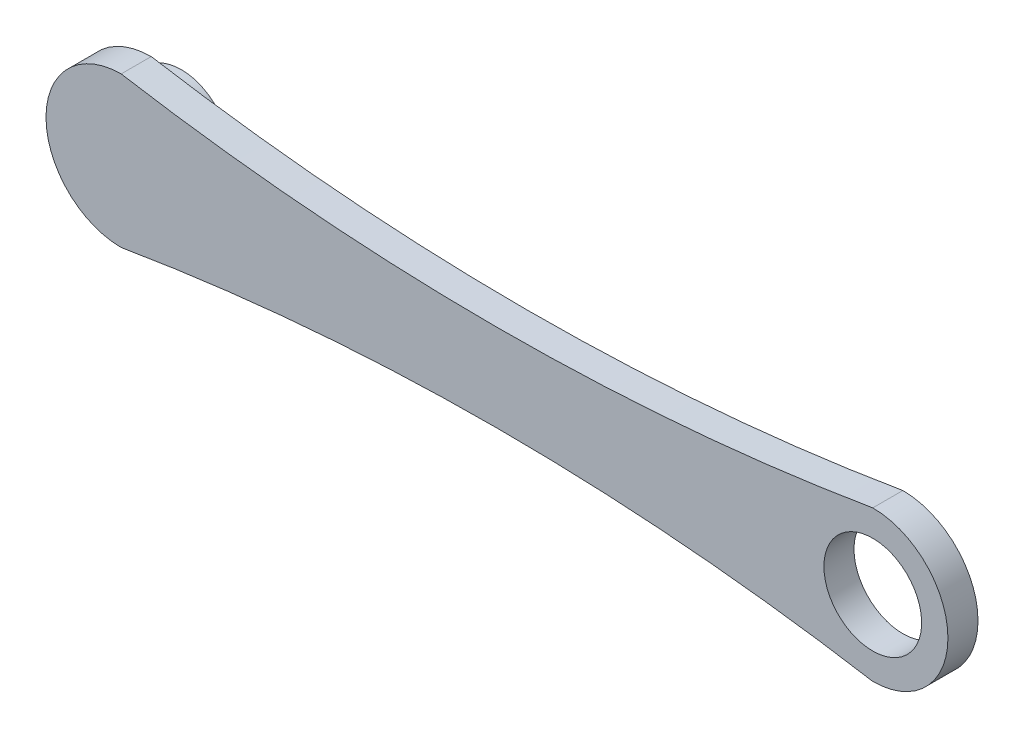
from build123d import *

# Parameters (mm, degrees)
BOSS_EXTRUDE1_DEPTH = 10
SKETCH2_R           = 16.25
BOSS_EXTRUDE2_DEPTH = 10
SKETCH3_R           = 16.25
CUT_EXTRUDE1_DEPTH  = 10


with BuildPart() as part:
    # Sketch1 → Boss-Extrude1 (new body)
    with BuildSketch(Plane.XY):
        with BuildLine():
            ThreePointArc((-125, 25), (-150, 0), (-125, -25))
            ThreePointArc((-125, -25), (0, -14.509972887), (125, -25))
            ThreePointArc((125, -25), (150, 0), (125, 25))
            ThreePointArc((125, 25), (0, 14.509972887), (-125, 25))
        make_face()
    extrude(amount=BOSS_EXTRUDE1_DEPTH)

    # Sketch2 → Boss-Extrude2 (add)
    with BuildSketch(Plane(origin=(0, 0, 0), x_dir=(1, 0, 0), z_dir=(0, 0, -1))):
        with Locations((-125, 0)):
            Circle(SKETCH2_R)
    extrude(amount=BOSS_EXTRUDE2_DEPTH)

    # Sketch3 → Cut-Extrude1 (cut)
    with BuildSketch(Plane.XY.offset(10)):
        with Locations((125, 0)):
            Circle(SKETCH3_R)
    extrude(amount=-CUT_EXTRUDE1_DEPTH, mode=Mode.SUBTRACT)


solid = part.part
